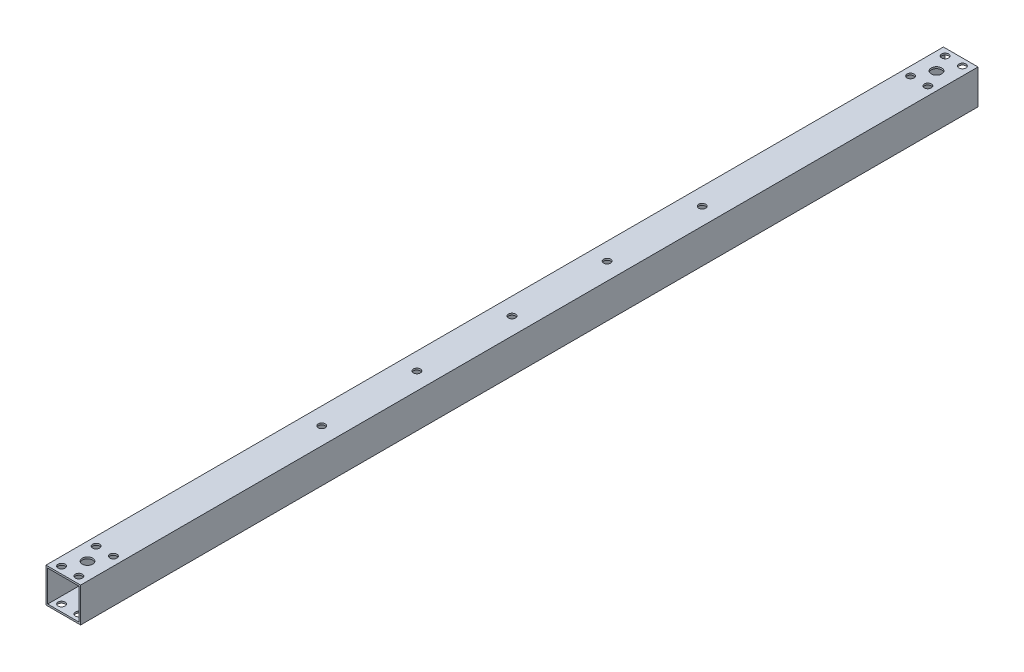
from build123d import *

# Parameters (mm, degrees)
SKETCH_1_W          = 20
SKETCH_1_H          = 20
SKETCH_1_W_2        = 18
SKETCH_1_H_2        = 18
EXTRUDE_1_DEPTH     = 259.5
SKETCH_2_R          = 2.025
SKETCH_2_R_2        = 3.025
CUT_EXTRUDE_1_DEPTH = 20
SKETCH_3_R          = 2.025
CUT_EXTRUDE_2_DEPTH = 20


with BuildPart() as part:
    # 草图1 → 凸台-拉伸1 (new body, symmetric)
    with BuildSketch(Plane.XY):
        Rectangle(SKETCH_1_W, SKETCH_1_H)
        Rectangle(SKETCH_1_W_2, SKETCH_1_H_2, mode=Mode.SUBTRACT)
    extrude(amount=EXTRUDE_1_DEPTH, both=True)

    # 草图2 → 切除-拉伸1 (cut, symmetric)
    with BuildSketch(Plane(origin=(0, 10, 0), x_dir=(1, 0, 0), z_dir=(0, 1, 0))):
        with Locations((-5, 255.5)):
            Circle(SKETCH_2_R)
        with Locations((5, 255.5)):
            Circle(SKETCH_2_R)
        with Locations((-5, 235.5)):
            Circle(SKETCH_2_R)
        with Locations((5, 235.5)):
            Circle(SKETCH_2_R)
        with Locations((0, 245.5)):
            Circle(SKETCH_2_R_2)
        with Locations((5, -235.5)):
            Circle(SKETCH_2_R)
        with Locations((-5, -235.5)):
            Circle(SKETCH_2_R)
        with Locations((-5, -255.5)):
            Circle(SKETCH_2_R)
        with Locations((0, -245.5)):
            Circle(SKETCH_2_R_2)
        with Locations((5, -255.5)):
            Circle(SKETCH_2_R)
    extrude(amount=CUT_EXTRUDE_1_DEPTH, both=True, mode=Mode.SUBTRACT)

    # 草图3 → 切除-拉伸2 (cut)
    with BuildSketch(Plane(origin=(0, 10, 0), x_dir=(1, 0, 0), z_dir=(0, 1, 0))):
        with Locations((0, 110)):
            Circle(SKETCH_3_R)
        with Locations((0, 55)):
            Circle(SKETCH_3_R)
        Circle(SKETCH_3_R)
        with Locations((0, -55)):
            Circle(SKETCH_3_R)
        with Locations((0, -110)):
            Circle(SKETCH_3_R)
    extrude(amount=-CUT_EXTRUDE_2_DEPTH, mode=Mode.SUBTRACT)


solid = part.part
